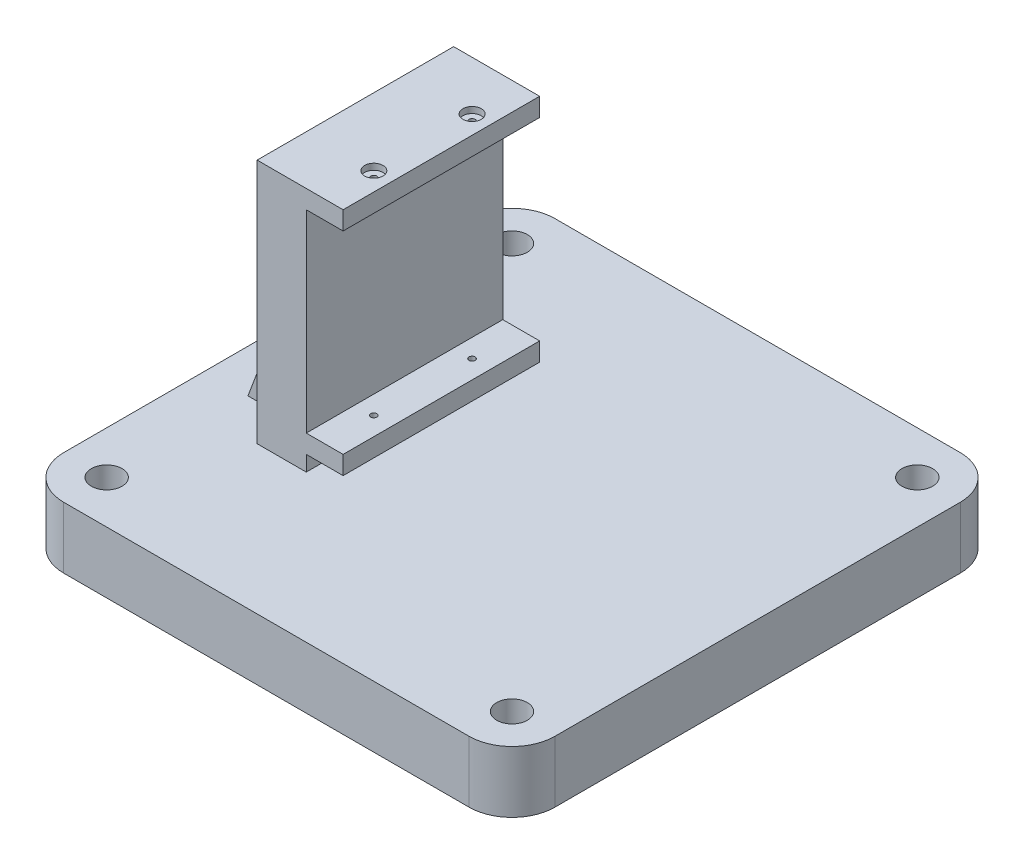
from build123d import *

# Parameters (mm, degrees)
SKETCH1_R           = 2.5
BOSS_EXTRUDE1_DEPTH = 10
SKETCH5_W           = 8
SKETCH5_H           = 32
BOSS_EXTRUDE4_DEPTH = 40
BOSS_EXTRUDE5_DEPTH = 10
SKETCH7_W           = 32
SKETCH7_H           = 3
BOSS_EXTRUDE6_DEPTH = 6
SKETCH8_R           = 0.5
CUT_EXTRUDE1_DEPTH  = 39
SKETCH9_R           = 1.5
CUT_EXTRUDE2_DEPTH  = 1


with BuildPart() as part:
    # Sketch1 → Boss-Extrude1 (new body)
    with BuildSketch(Plane(origin=(0, 0, 0), x_dir=(1, 0, 0), z_dir=(0, 1, 0))):
        with BuildLine():
            Line((-33, -40), (33, -40))
            ThreePointArc((33, -40), (37.949747468, -37.949747468), (40, -33))
            Line((40, -33), (40, 33))
            ThreePointArc((40, 33), (37.949747468, 37.949747468), (33, 40))
            Line((33, 40), (-33, 40))
            ThreePointArc((-33, 40), (-37.949747468, 37.949747468), (-40, 33))
            Line((-40, 33), (-40, -33))
            ThreePointArc((-40, -33), (-37.949747468, -37.949747468), (-33, -40))
        make_face()
        with Locations((33, -33)):
            Circle(SKETCH1_R, mode=Mode.SUBTRACT)
        with Locations((-33, -33)):
            Circle(SKETCH1_R, mode=Mode.SUBTRACT)
        with Locations((33, 33)):
            Circle(SKETCH1_R, mode=Mode.SUBTRACT)
        with Locations((-33, 33)):
            Circle(SKETCH1_R, mode=Mode.SUBTRACT)
    extrude(amount=BOSS_EXTRUDE1_DEPTH)

    # Sketch5 → Boss-Extrude4 (add)
    with BuildSketch(Plane(origin=(0, 10, 0), x_dir=(1, 0, 0), z_dir=(0, 1, 0))):
        with Locations((-21.5, 0)):
            Rectangle(SKETCH5_W, SKETCH5_H)
    extrude(amount=BOSS_EXTRUDE4_DEPTH)

    # Sketch6 → Boss-Extrude5 (add, symmetric)
    with BuildSketch(Plane.XY):
        Polygon((-33, 10), (-25.5, 30), (-25.5, 10), align=None)
    extrude(amount=BOSS_EXTRUDE5_DEPTH, both=True)

    # Sketch7 → Boss-Extrude6 (add)
    with BuildSketch(Plane(origin=(-17.5, 0, 0), x_dir=(0, 0, -1), z_dir=(1, 0, 0))):
        with Locations((0, 48.5)):
            Rectangle(SKETCH7_W, SKETCH7_H)
        with Locations((0, 14)):
            Rectangle(SKETCH7_W, SKETCH7_H)
    extrude(amount=BOSS_EXTRUDE6_DEPTH)

    # Sketch8 → Cut-Extrude1 (cut)
    with BuildSketch(Plane(origin=(0, 50, 0), x_dir=(1, 0, 0), z_dir=(0, 1, 0))):
        with Locations((-14.5, -8)):
            Circle(SKETCH8_R)
        with Locations((-14.5, 8)):
            Circle(SKETCH8_R)
    extrude(amount=-CUT_EXTRUDE1_DEPTH, mode=Mode.SUBTRACT)

    # Sketch9 → Cut-Extrude2 (cut)
    with BuildSketch(Plane(origin=(0, 50, 0), x_dir=(1, 0, 0), z_dir=(0, 1, 0))):
        with Locations((-14.5, 8)):
            Circle(SKETCH9_R)
        with Locations((-14.5, -8)):
            Circle(SKETCH9_R)
    extrude(amount=-CUT_EXTRUDE2_DEPTH, mode=Mode.SUBTRACT)


solid = part.part
